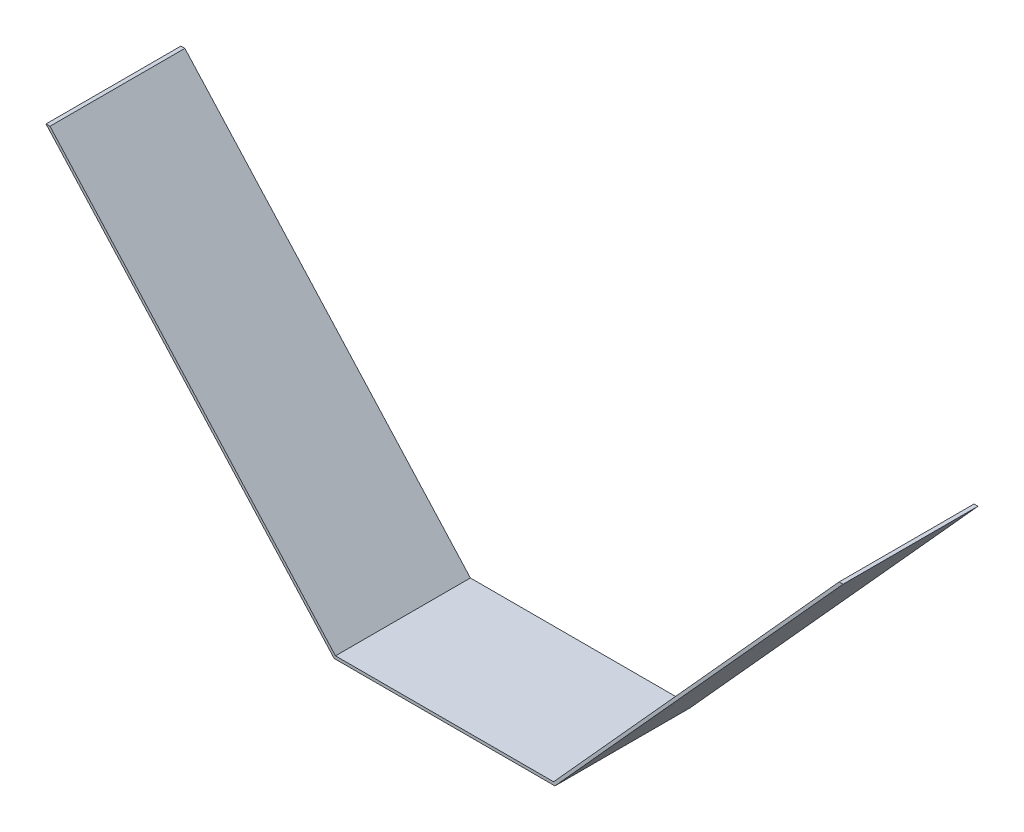
from build123d import *

# Parameters (mm, degrees)
BOSS_EXTRUDE1_DEPTH = 69.85
SHELL10_T           = -1.524


with BuildPart() as part:
    # Sketch1 → Boss-Extrude1 (new body)
    with BuildSketch(Plane.XY):
        Polygon((-374.797674419, 95.508430233), (37.952325581, 95.508430233), (-111.272674419, -69.591569767), (-225.572674419, -69.591569767), align=None)
    extrude(amount=BOSS_EXTRUDE1_DEPTH)

    # Shell10
    shell10_openings = [part.faces().sort_by_distance(p)[0] for p in [
        (-168.422674419, 12.958430233, 69.85),
        (-168.422674419, 12.958430233, 0),
        (-168.422674419, 95.508430233, 34.925),
    ]]
    offset(amount=SHELL10_T, openings=shell10_openings, kind=Kind.INTERSECTION)


solid = part.part
